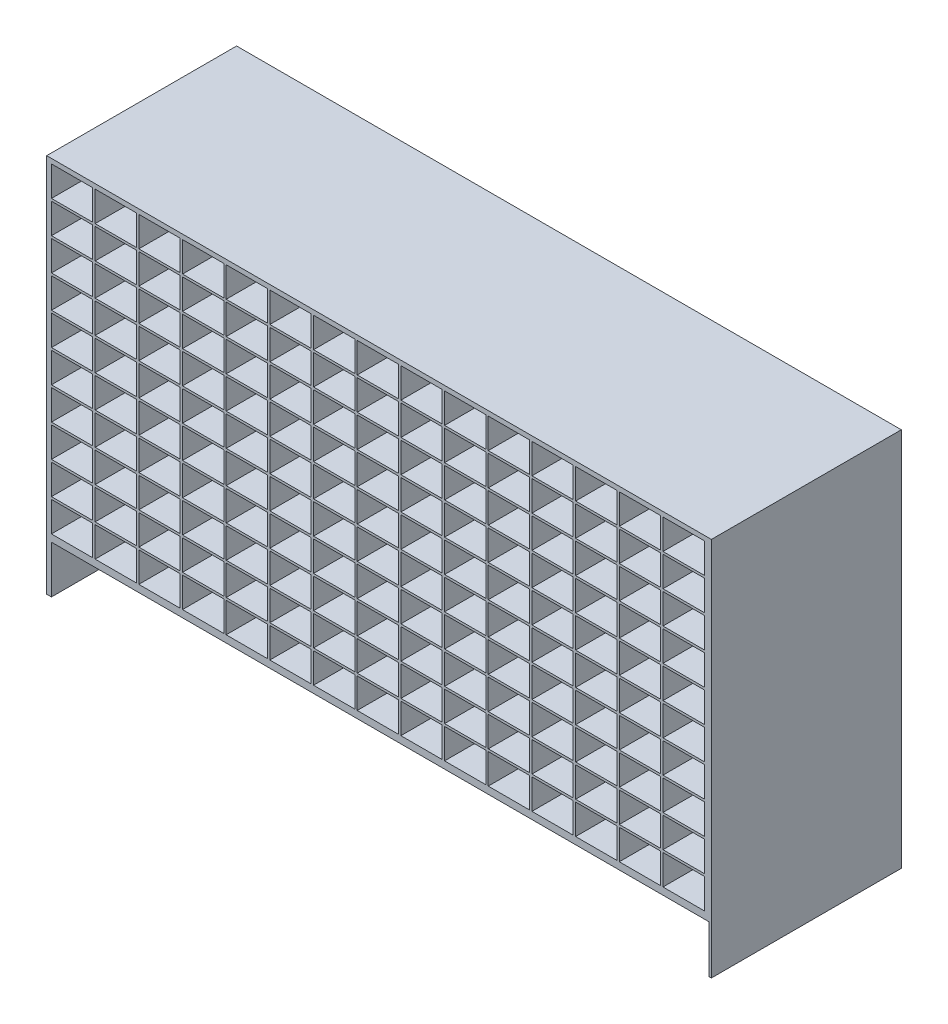
from build123d import *

# Parameters (mm, degrees)
CROQUIS1_W              = 3500
CROQUIS1_H              = 2000
SALIENTE_EXTRUIR1_DEPTH = 1000
CROQUIS2_W              = 3462.5
CROQUIS2_H              = 250
CORTAR_EXTRUIR1_DEPTH   = 975
CROQUIS3_W              = 217.5
CROQUIS3_H              = 157.5
CORTAR_EXTRUIR2_DEPTH   = 1001


with BuildPart() as part:
    # Croquis1 → Saliente-Extruir1 (new body)
    with BuildSketch(Plane.XY):
        with Locations((1750, 1000)):
            Rectangle(CROQUIS1_W, CROQUIS1_H)
    extrude(amount=-SALIENTE_EXTRUIR1_DEPTH)

    # Croquis2 → Cortar-Extruir1 (cut)
    with BuildSketch(Plane.XY):
        with Locations((1756.25, 125)):
            Rectangle(CROQUIS2_W, CROQUIS2_H)
    extrude(amount=-CORTAR_EXTRUIR1_DEPTH, mode=Mode.SUBTRACT)

    # Croquis3 → Cortar-Extruir2 (cut, through all)
    with BuildSketch(Plane.XY):
        with Locations((363.75, 1896.25)):
            Rectangle(CROQUIS3_W, CROQUIS3_H)
        with Locations((133.75, 1896.25)):
            Rectangle(CROQUIS3_W, CROQUIS3_H)
        with Locations((593.75, 1896.25)):
            Rectangle(CROQUIS3_W, CROQUIS3_H)
        with Locations((823.75, 1896.25)):
            Rectangle(CROQUIS3_W, CROQUIS3_H)
        with Locations((1053.75, 1896.25)):
            Rectangle(CROQUIS3_W, CROQUIS3_H)
        with Locations((1283.75, 1896.25)):
            Rectangle(CROQUIS3_W, CROQUIS3_H)
        with Locations((1513.75, 1896.25)):
            Rectangle(CROQUIS3_W, CROQUIS3_H)
        with Locations((1743.75, 1896.25)):
            Rectangle(CROQUIS3_W, CROQUIS3_H)
        with Locations((1973.75, 1896.25)):
            Rectangle(CROQUIS3_W, CROQUIS3_H)
        with Locations((2203.75, 1896.25)):
            Rectangle(CROQUIS3_W, CROQUIS3_H)
        with Locations((2433.75, 1896.25)):
            Rectangle(CROQUIS3_W, CROQUIS3_H)
        with Locations((2663.75, 1896.25)):
            Rectangle(CROQUIS3_W, CROQUIS3_H)
        with Locations((2893.75, 1896.25)):
            Rectangle(CROQUIS3_W, CROQUIS3_H)
        with Locations((3123.75, 1896.25)):
            Rectangle(CROQUIS3_W, CROQUIS3_H)
        with Locations((3353.75, 1896.25)):
            Rectangle(CROQUIS3_W, CROQUIS3_H)
        with Locations((363.75, 1726.25)):
            Rectangle(CROQUIS3_W, CROQUIS3_H)
        with Locations((593.75, 1726.25)):
            Rectangle(CROQUIS3_W, CROQUIS3_H)
        with Locations((823.75, 1726.25)):
            Rectangle(CROQUIS3_W, CROQUIS3_H)
        with Locations((1053.75, 1726.25)):
            Rectangle(CROQUIS3_W, CROQUIS3_H)
        with Locations((1283.75, 1726.25)):
            Rectangle(CROQUIS3_W, CROQUIS3_H)
        with Locations((1513.75, 1726.25)):
            Rectangle(CROQUIS3_W, CROQUIS3_H)
        with Locations((1743.75, 1726.25)):
            Rectangle(CROQUIS3_W, CROQUIS3_H)
        with Locations((1973.75, 1726.25)):
            Rectangle(CROQUIS3_W, CROQUIS3_H)
        with Locations((2203.75, 1726.25)):
            Rectangle(CROQUIS3_W, CROQUIS3_H)
        with Locations((2433.75, 1726.25)):
            Rectangle(CROQUIS3_W, CROQUIS3_H)
        with Locations((2663.75, 1726.25)):
            Rectangle(CROQUIS3_W, CROQUIS3_H)
        with Locations((2893.75, 1726.25)):
            Rectangle(CROQUIS3_W, CROQUIS3_H)
        with Locations((3123.75, 1726.25)):
            Rectangle(CROQUIS3_W, CROQUIS3_H)
        with Locations((3353.75, 1726.25)):
            Rectangle(CROQUIS3_W, CROQUIS3_H)
        with Locations((363.75, 1556.25)):
            Rectangle(CROQUIS3_W, CROQUIS3_H)
        with Locations((593.75, 1556.25)):
            Rectangle(CROQUIS3_W, CROQUIS3_H)
        with Locations((823.75, 1556.25)):
            Rectangle(CROQUIS3_W, CROQUIS3_H)
        with Locations((1053.75, 1556.25)):
            Rectangle(CROQUIS3_W, CROQUIS3_H)
        with Locations((1283.75, 1556.25)):
            Rectangle(CROQUIS3_W, CROQUIS3_H)
        with Locations((1513.75, 1556.25)):
            Rectangle(CROQUIS3_W, CROQUIS3_H)
        with Locations((1743.75, 1556.25)):
            Rectangle(CROQUIS3_W, CROQUIS3_H)
        with Locations((1973.75, 1556.25)):
            Rectangle(CROQUIS3_W, CROQUIS3_H)
        with Locations((2203.75, 1556.25)):
            Rectangle(CROQUIS3_W, CROQUIS3_H)
        with Locations((2433.75, 1556.25)):
            Rectangle(CROQUIS3_W, CROQUIS3_H)
        with Locations((2663.75, 1556.25)):
            Rectangle(CROQUIS3_W, CROQUIS3_H)
        with Locations((2893.75, 1556.25)):
            Rectangle(CROQUIS3_W, CROQUIS3_H)
        with Locations((3123.75, 1556.25)):
            Rectangle(CROQUIS3_W, CROQUIS3_H)
        with Locations((3353.75, 1556.25)):
            Rectangle(CROQUIS3_W, CROQUIS3_H)
        with Locations((363.75, 1386.25)):
            Rectangle(CROQUIS3_W, CROQUIS3_H)
        with Locations((593.75, 1386.25)):
            Rectangle(CROQUIS3_W, CROQUIS3_H)
        with Locations((823.75, 1386.25)):
            Rectangle(CROQUIS3_W, CROQUIS3_H)
        with Locations((1053.75, 1386.25)):
            Rectangle(CROQUIS3_W, CROQUIS3_H)
        with Locations((1283.75, 1386.25)):
            Rectangle(CROQUIS3_W, CROQUIS3_H)
        with Locations((1513.75, 1386.25)):
            Rectangle(CROQUIS3_W, CROQUIS3_H)
        with Locations((1743.75, 1386.25)):
            Rectangle(CROQUIS3_W, CROQUIS3_H)
        with Locations((1973.75, 1386.25)):
            Rectangle(CROQUIS3_W, CROQUIS3_H)
        with Locations((2203.75, 1386.25)):
            Rectangle(CROQUIS3_W, CROQUIS3_H)
        with Locations((2433.75, 1386.25)):
            Rectangle(CROQUIS3_W, CROQUIS3_H)
        with Locations((2663.75, 1386.25)):
            Rectangle(CROQUIS3_W, CROQUIS3_H)
        with Locations((2893.75, 1386.25)):
            Rectangle(CROQUIS3_W, CROQUIS3_H)
        with Locations((3123.75, 1386.25)):
            Rectangle(CROQUIS3_W, CROQUIS3_H)
        with Locations((3353.75, 1386.25)):
            Rectangle(CROQUIS3_W, CROQUIS3_H)
        with Locations((363.75, 1216.25)):
            Rectangle(CROQUIS3_W, CROQUIS3_H)
        with Locations((593.75, 1216.25)):
            Rectangle(CROQUIS3_W, CROQUIS3_H)
        with Locations((823.75, 1216.25)):
            Rectangle(CROQUIS3_W, CROQUIS3_H)
        with Locations((1053.75, 1216.25)):
            Rectangle(CROQUIS3_W, CROQUIS3_H)
        with Locations((1283.75, 1216.25)):
            Rectangle(CROQUIS3_W, CROQUIS3_H)
        with Locations((1513.75, 1216.25)):
            Rectangle(CROQUIS3_W, CROQUIS3_H)
        with Locations((1743.75, 1216.25)):
            Rectangle(CROQUIS3_W, CROQUIS3_H)
        with Locations((1973.75, 1216.25)):
            Rectangle(CROQUIS3_W, CROQUIS3_H)
        with Locations((2203.75, 1216.25)):
            Rectangle(CROQUIS3_W, CROQUIS3_H)
        with Locations((2433.75, 1216.25)):
            Rectangle(CROQUIS3_W, CROQUIS3_H)
        with Locations((2663.75, 1216.25)):
            Rectangle(CROQUIS3_W, CROQUIS3_H)
        with Locations((2893.75, 1216.25)):
            Rectangle(CROQUIS3_W, CROQUIS3_H)
        with Locations((3123.75, 1216.25)):
            Rectangle(CROQUIS3_W, CROQUIS3_H)
        with Locations((3353.75, 1216.25)):
            Rectangle(CROQUIS3_W, CROQUIS3_H)
        with Locations((363.75, 1046.25)):
            Rectangle(CROQUIS3_W, CROQUIS3_H)
        with Locations((593.75, 1046.25)):
            Rectangle(CROQUIS3_W, CROQUIS3_H)
        with Locations((823.75, 1046.25)):
            Rectangle(CROQUIS3_W, CROQUIS3_H)
        with Locations((1053.75, 1046.25)):
            Rectangle(CROQUIS3_W, CROQUIS3_H)
        with Locations((1283.75, 1046.25)):
            Rectangle(CROQUIS3_W, CROQUIS3_H)
        with Locations((1513.75, 1046.25)):
            Rectangle(CROQUIS3_W, CROQUIS3_H)
        with Locations((1743.75, 1046.25)):
            Rectangle(CROQUIS3_W, CROQUIS3_H)
        with Locations((1973.75, 1046.25)):
            Rectangle(CROQUIS3_W, CROQUIS3_H)
        with Locations((2203.75, 1046.25)):
            Rectangle(CROQUIS3_W, CROQUIS3_H)
        with Locations((2433.75, 1046.25)):
            Rectangle(CROQUIS3_W, CROQUIS3_H)
        with Locations((2663.75, 1046.25)):
            Rectangle(CROQUIS3_W, CROQUIS3_H)
        with Locations((2893.75, 1046.25)):
            Rectangle(CROQUIS3_W, CROQUIS3_H)
        with Locations((3123.75, 1046.25)):
            Rectangle(CROQUIS3_W, CROQUIS3_H)
        with Locations((3353.75, 1046.25)):
            Rectangle(CROQUIS3_W, CROQUIS3_H)
        with Locations((363.75, 876.25)):
            Rectangle(CROQUIS3_W, CROQUIS3_H)
        with Locations((593.75, 876.25)):
            Rectangle(CROQUIS3_W, CROQUIS3_H)
        with Locations((823.75, 876.25)):
            Rectangle(CROQUIS3_W, CROQUIS3_H)
        with Locations((1053.75, 876.25)):
            Rectangle(CROQUIS3_W, CROQUIS3_H)
        with Locations((1283.75, 876.25)):
            Rectangle(CROQUIS3_W, CROQUIS3_H)
        with Locations((1513.75, 876.25)):
            Rectangle(CROQUIS3_W, CROQUIS3_H)
        with Locations((1743.75, 876.25)):
            Rectangle(CROQUIS3_W, CROQUIS3_H)
        with Locations((1973.75, 876.25)):
            Rectangle(CROQUIS3_W, CROQUIS3_H)
        with Locations((2203.75, 876.25)):
            Rectangle(CROQUIS3_W, CROQUIS3_H)
        with Locations((2433.75, 876.25)):
            Rectangle(CROQUIS3_W, CROQUIS3_H)
        with Locations((2663.75, 876.25)):
            Rectangle(CROQUIS3_W, CROQUIS3_H)
        with Locations((2893.75, 876.25)):
            Rectangle(CROQUIS3_W, CROQUIS3_H)
        with Locations((3123.75, 876.25)):
            Rectangle(CROQUIS3_W, CROQUIS3_H)
        with Locations((3353.75, 876.25)):
            Rectangle(CROQUIS3_W, CROQUIS3_H)
        with Locations((363.75, 706.25)):
            Rectangle(CROQUIS3_W, CROQUIS3_H)
        with Locations((593.75, 706.25)):
            Rectangle(CROQUIS3_W, CROQUIS3_H)
        with Locations((823.75, 706.25)):
            Rectangle(CROQUIS3_W, CROQUIS3_H)
        with Locations((1053.75, 706.25)):
            Rectangle(CROQUIS3_W, CROQUIS3_H)
        with Locations((1283.75, 706.25)):
            Rectangle(CROQUIS3_W, CROQUIS3_H)
        with Locations((1513.75, 706.25)):
            Rectangle(CROQUIS3_W, CROQUIS3_H)
        with Locations((1743.75, 706.25)):
            Rectangle(CROQUIS3_W, CROQUIS3_H)
        with Locations((1973.75, 706.25)):
            Rectangle(CROQUIS3_W, CROQUIS3_H)
        with Locations((2203.75, 706.25)):
            Rectangle(CROQUIS3_W, CROQUIS3_H)
        with Locations((2433.75, 706.25)):
            Rectangle(CROQUIS3_W, CROQUIS3_H)
        with Locations((2663.75, 706.25)):
            Rectangle(CROQUIS3_W, CROQUIS3_H)
        with Locations((2893.75, 706.25)):
            Rectangle(CROQUIS3_W, CROQUIS3_H)
        with Locations((3123.75, 706.25)):
            Rectangle(CROQUIS3_W, CROQUIS3_H)
        with Locations((3353.75, 706.25)):
            Rectangle(CROQUIS3_W, CROQUIS3_H)
        with Locations((363.75, 536.25)):
            Rectangle(CROQUIS3_W, CROQUIS3_H)
        with Locations((593.75, 536.25)):
            Rectangle(CROQUIS3_W, CROQUIS3_H)
        with Locations((823.75, 536.25)):
            Rectangle(CROQUIS3_W, CROQUIS3_H)
        with Locations((1053.75, 536.25)):
            Rectangle(CROQUIS3_W, CROQUIS3_H)
        with Locations((1283.75, 536.25)):
            Rectangle(CROQUIS3_W, CROQUIS3_H)
        with Locations((1513.75, 536.25)):
            Rectangle(CROQUIS3_W, CROQUIS3_H)
        with Locations((1743.75, 536.25)):
            Rectangle(CROQUIS3_W, CROQUIS3_H)
        with Locations((1973.75, 536.25)):
            Rectangle(CROQUIS3_W, CROQUIS3_H)
        with Locations((2203.75, 536.25)):
            Rectangle(CROQUIS3_W, CROQUIS3_H)
        with Locations((2433.75, 536.25)):
            Rectangle(CROQUIS3_W, CROQUIS3_H)
        with Locations((2663.75, 536.25)):
            Rectangle(CROQUIS3_W, CROQUIS3_H)
        with Locations((2893.75, 536.25)):
            Rectangle(CROQUIS3_W, CROQUIS3_H)
        with Locations((3123.75, 536.25)):
            Rectangle(CROQUIS3_W, CROQUIS3_H)
        with Locations((3353.75, 536.25)):
            Rectangle(CROQUIS3_W, CROQUIS3_H)
        with Locations((363.75, 366.25)):
            Rectangle(CROQUIS3_W, CROQUIS3_H)
        with Locations((593.75, 366.25)):
            Rectangle(CROQUIS3_W, CROQUIS3_H)
        with Locations((823.75, 366.25)):
            Rectangle(CROQUIS3_W, CROQUIS3_H)
        with Locations((1053.75, 366.25)):
            Rectangle(CROQUIS3_W, CROQUIS3_H)
        with Locations((1283.75, 366.25)):
            Rectangle(CROQUIS3_W, CROQUIS3_H)
        with Locations((1513.75, 366.25)):
            Rectangle(CROQUIS3_W, CROQUIS3_H)
        with Locations((1743.75, 366.25)):
            Rectangle(CROQUIS3_W, CROQUIS3_H)
        with Locations((1973.75, 366.25)):
            Rectangle(CROQUIS3_W, CROQUIS3_H)
        with Locations((2203.75, 366.25)):
            Rectangle(CROQUIS3_W, CROQUIS3_H)
        with Locations((2433.75, 366.25)):
            Rectangle(CROQUIS3_W, CROQUIS3_H)
        with Locations((2663.75, 366.25)):
            Rectangle(CROQUIS3_W, CROQUIS3_H)
        with Locations((2893.75, 366.25)):
            Rectangle(CROQUIS3_W, CROQUIS3_H)
        with Locations((3123.75, 366.25)):
            Rectangle(CROQUIS3_W, CROQUIS3_H)
        with Locations((3353.75, 366.25)):
            Rectangle(CROQUIS3_W, CROQUIS3_H)
        with Locations((133.75, 1726.25)):
            Rectangle(CROQUIS3_W, CROQUIS3_H)
        with Locations((133.75, 1556.25)):
            Rectangle(CROQUIS3_W, CROQUIS3_H)
        with Locations((133.75, 1386.25)):
            Rectangle(CROQUIS3_W, CROQUIS3_H)
        with Locations((133.75, 1216.25)):
            Rectangle(CROQUIS3_W, CROQUIS3_H)
        with Locations((133.75, 1046.25)):
            Rectangle(CROQUIS3_W, CROQUIS3_H)
        with Locations((133.75, 876.25)):
            Rectangle(CROQUIS3_W, CROQUIS3_H)
        with Locations((133.75, 706.25)):
            Rectangle(CROQUIS3_W, CROQUIS3_H)
        with Locations((133.75, 536.25)):
            Rectangle(CROQUIS3_W, CROQUIS3_H)
        with Locations((133.75, 366.25)):
            Rectangle(CROQUIS3_W, CROQUIS3_H)
    extrude(amount=-CORTAR_EXTRUIR2_DEPTH, mode=Mode.SUBTRACT)


solid = part.part
